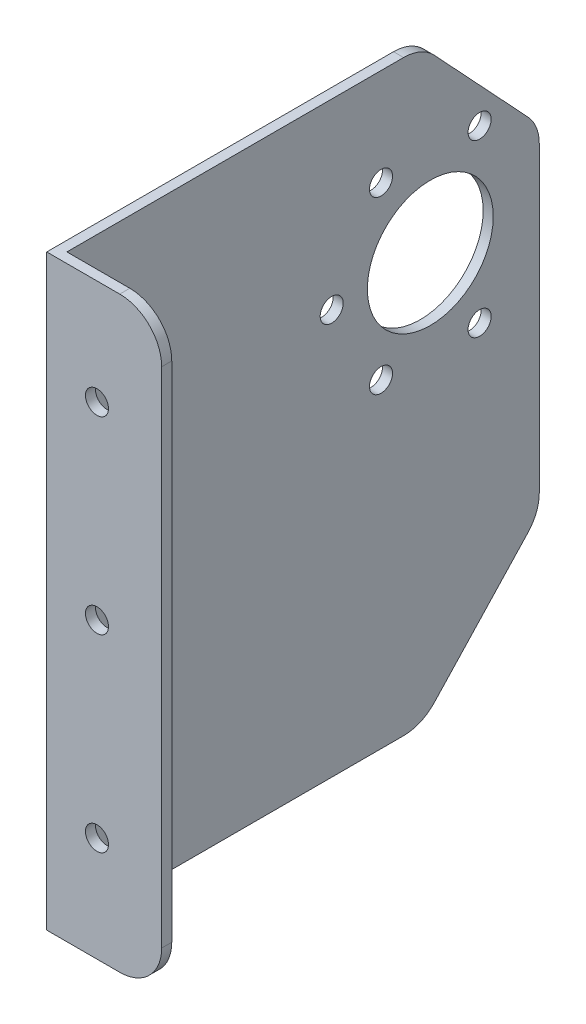
from build123d import *

# Parameters (mm, degrees)
SKETCH1_W           = 115
SKETCH1_H           = 140
BOSS_EXTRUDE1_DEPTH = 2.4
CUT_EXTRUDE1_DEPTH  = 3.4
FILLET1_R           = 10
SKETCH3_W           = 2.4
SKETCH3_H           = 140
BOSS_EXTRUDE2_DEPTH = 25
FILLET2_R           = 10
SKETCH4_R           = 2.75
CUT_EXTRUDE2_DEPTH  = 116
SKETCH5_R           = 15
SKETCH5_R_2         = 2.75
CUT_EXTRUDE3_DEPTH  = 3.4


with BuildPart() as part:
    # Sketch1 → Boss-Extrude1 (new body)
    with BuildSketch(Plane(origin=(0, 0, 0), x_dir=(0, 0, -1), z_dir=(1, 0, 0))):
        with Locations((57.5, -70)):
            Rectangle(SKETCH1_W, SKETCH1_H)
    extrude(amount=BOSS_EXTRUDE1_DEPTH)

    # Sketch2 → Cut-Extrude1 (cut, through all)
    with BuildSketch(Plane(origin=(2.4, 0, 0), x_dir=(0, 0, -1), z_dir=(1, 0, 0))):
        Polygon((87, 0), (115, -30), (142.616199658, -32.505405645), (142.616199658, 14.875556406), align=None)
        Polygon((115, -110), (87, -140), (87, -152.661109726), (136.310004643, -152.661109726), align=None)
    extrude(amount=-CUT_EXTRUDE1_DEPTH, mode=Mode.SUBTRACT)

    # Fillet1
    fillet1_edges = [part.edges().sort_by_distance(p)[0] for p in [
        (1.2, 0, -87),
        (1.2, -30, -115),
        (1.2, -110, -115),
        (1.2, -140, -87),
    ]]
    fillet(fillet1_edges, radius=FILLET1_R)

    # Sketch3 → Boss-Extrude2 (add)
    with BuildSketch(Plane(origin=(2.4, 0, 0), x_dir=(0, 0, -1), z_dir=(1, 0, 0))):
        with Locations((1.2, -70)):
            Rectangle(SKETCH3_W, SKETCH3_H)
    extrude(amount=BOSS_EXTRUDE2_DEPTH)

    # Fillet2
    fillet2_edges = [part.edges().sort_by_distance(p)[0] for p in [
        (27.4, -140, -1.2),
        (27.4, 0, -1.2),
    ]]
    fillet(fillet2_edges, radius=FILLET2_R)

    # Sketch4 → Cut-Extrude2 (cut, through all)
    with BuildSketch(Plane.XY):
        with Locations((11.974983581, -70)):
            Circle(SKETCH4_R)
        with Locations((11.974983581, -25)):
            Circle(SKETCH4_R)
        with Locations((11.974983581, -115)):
            Circle(SKETCH4_R)
    extrude(amount=-CUT_EXTRUDE2_DEPTH, mode=Mode.SUBTRACT)

    # Sketch5 → Cut-Extrude3 (cut, through all)
    with BuildSketch(Plane(origin=(2.4, 0, 0), x_dir=(0, 0, -1), z_dir=(1, 0, 0))):
        with Locations((89.027947804, -43.505970801)):
            Circle(SKETCH5_R)
        with Locations((77.277947804, -23.154373812)):
            Circle(SKETCH5_R_2)
        with Locations((100.777947804, -23.154373812)):
            Circle(SKETCH5_R_2)
        with Locations((65.527947804, -43.505970801)):
            Circle(SKETCH5_R_2)
        with Locations((77.277947804, -63.85756779)):
            Circle(SKETCH5_R_2)
        with Locations((100.777947804, -63.85756779)):
            Circle(SKETCH5_R_2)
    extrude(amount=-CUT_EXTRUDE3_DEPTH, mode=Mode.SUBTRACT)


solid = part.part
